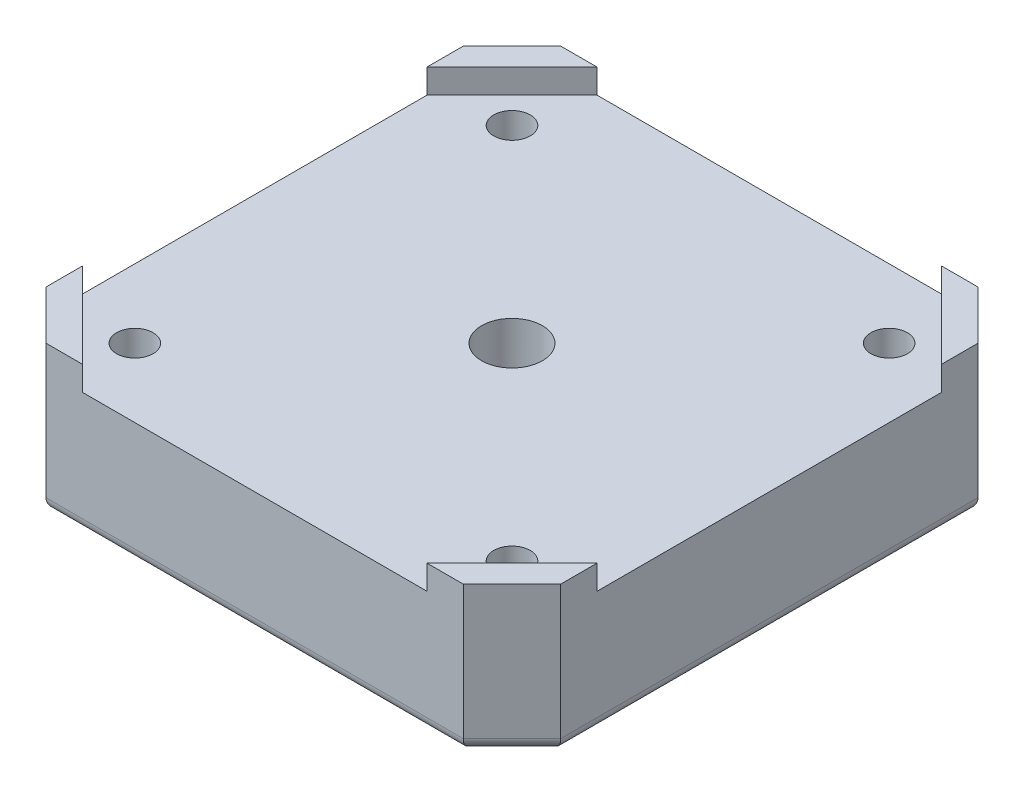
from build123d import *

# Parameters (mm, degrees)
BOSS_EXTRUDE3_DEPTH = 12
CUT_EXTRUDE5_DEPTH  = 2
SKETCH12_R          = 2.5
CUT_EXTRUDE6_DEPTH  = 11
SKETCH13_R          = 5.5
CUT_EXTRUDE7_DEPTH  = 5
SKETCH14_R          = 1.5
CUT_EXTRUDE8_DEPTH  = 13
SKETCH15_R          = 3.1
CUT_EXTRUDE9_DEPTH  = 2.6
FILLET1_R           = 1
FILLET2_R           = 0.5


with BuildPart() as part:
    # Sketch10 → Boss-Extrude3 (new body)
    with BuildSketch(Plane(origin=(0, 0, 0), x_dir=(1, 0, 0), z_dir=(0, 1, 0))):
        Polygon((-21.15, 17.15), (-17.15, 21.15), (17.15, 21.15), (21.15, 17.15), (21.15, -17.15), (17.15, -21.15), (-17.15, -21.15), (-21.15, -17.15), align=None)
    extrude(amount=BOSS_EXTRUDE3_DEPTH)

    # Sketch11 → Cut-Extrude5 (cut)
    with BuildSketch(Plane(origin=(0, 12, 0), x_dir=(1, 0, 0), z_dir=(0, 1, 0))):
        Polygon((-14.15, -21.15), (14.15, -21.15), (21.15, -14.15), (21.15, 14.15), (14.15, 21.15), (-14.15, 21.15), (-21.15, 14.15), (-21.15, -14.15), align=None)
    extrude(amount=-CUT_EXTRUDE5_DEPTH, mode=Mode.SUBTRACT)

    # Sketch12 → Cut-Extrude6 (cut, through all)
    with BuildSketch(Plane(origin=(0, 10, 0), x_dir=(1, 0, 0), z_dir=(0, 1, 0))):
        Circle(SKETCH12_R)
    extrude(amount=-CUT_EXTRUDE6_DEPTH, mode=Mode.SUBTRACT)

    # Sketch13 → Cut-Extrude7 (cut)
    with BuildSketch(Plane.XZ):
        Circle(SKETCH13_R)
    extrude(amount=-CUT_EXTRUDE7_DEPTH, mode=Mode.SUBTRACT)

    # Sketch14 → Cut-Extrude8 (cut, through all)
    with BuildSketch(Plane.XZ):
        with Locations((-15.5, 15.5)):
            Circle(SKETCH14_R)
        with Locations((15.5, 15.5)):
            Circle(SKETCH14_R)
        with Locations((15.5, -15.5)):
            Circle(SKETCH14_R)
        with Locations((-15.5, -15.5)):
            Circle(SKETCH14_R)
    extrude(amount=-CUT_EXTRUDE8_DEPTH, mode=Mode.SUBTRACT)

    # Sketch15 → Cut-Extrude9 (cut)
    with BuildSketch(Plane.XZ):
        with Locations((-15.5, 15.5)):
            Circle(SKETCH15_R)
        with Locations((15.5, 15.5)):
            Circle(SKETCH15_R)
        with Locations((15.5, -15.5)):
            Circle(SKETCH15_R)
        with Locations((-15.5, -15.5)):
            Circle(SKETCH15_R)
    extrude(amount=-CUT_EXTRUDE9_DEPTH, mode=Mode.SUBTRACT)

    # Fillet1
    fillet1_edges = [part.edges().sort_by_distance(p)[0] for p in [
        (-19.15, 0, -19.15),
        (0, 0, -21.15),
        (-5.5, 0, 0),
        (-5.5, 5, 0),
        (19.15, 0, -19.15),
        (21.15, 0, 0),
        (19.15, 0, 19.15),
        (0, 0, 21.15),
        (-19.15, 0, 19.15),
        (-21.15, 0, 0),
    ]]
    fillet(fillet1_edges, radius=FILLET1_R)

    # Fillet2
    fillet2_edges = [part.edges().sort_by_distance(p)[0] for p in [
        (-18.6, 0, -15.5),
        (-18.6, 0, 15.5),
        (12.4, 0, 15.5),
        (12.4, 0, -15.5),
    ]]
    fillet(fillet2_edges, radius=FILLET2_R)


solid = part.part
